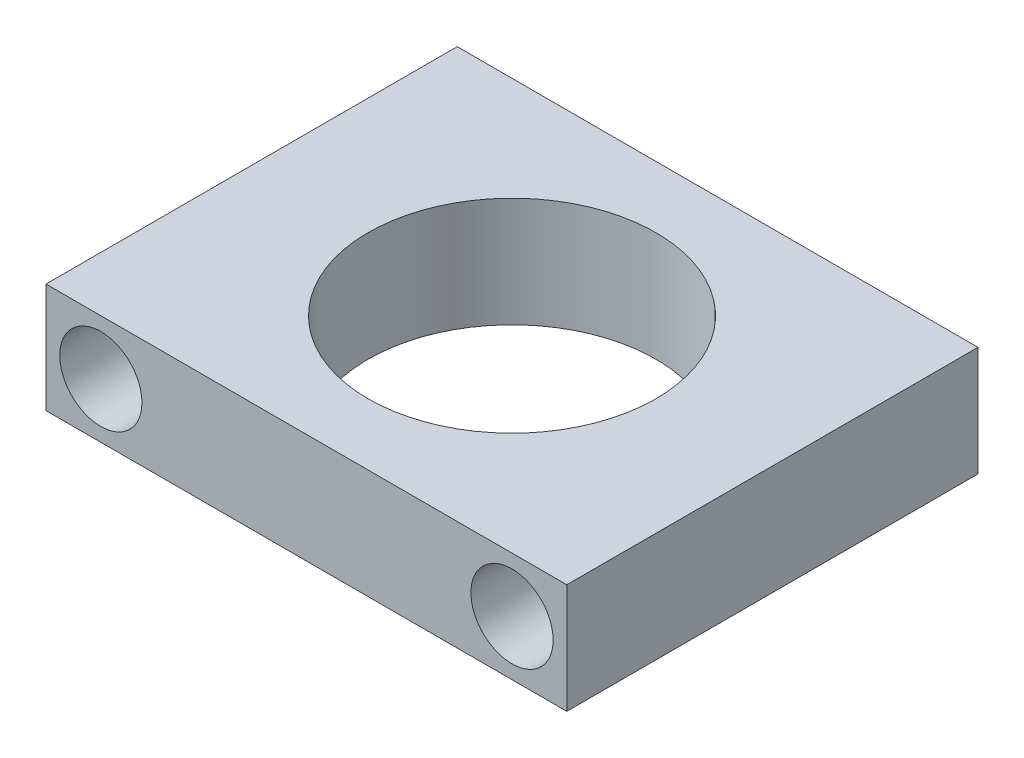
from build123d import *

# Parameters (mm, degrees)
SKETCH1_W           = 19
SKETCH1_H           = 15
SKETCH1_R           = 5.25
BOSS_EXTRUDE1_DEPTH = 4
SKETCH2_R           = 1.5
CUT_EXTRUDE1_DEPTH  = 15


with BuildPart() as part:
    # Sketch1 → Boss-Extrude1 (new body)
    with BuildSketch(Plane(origin=(0, 0, 0), x_dir=(1, 0, 0), z_dir=(0, 1, 0))):
        with Locations((9.5, 7.5)):
            Rectangle(SKETCH1_W, SKETCH1_H)
        with Locations((9.5, 7.5)):
            Circle(SKETCH1_R, mode=Mode.SUBTRACT)
    extrude(amount=BOSS_EXTRUDE1_DEPTH)

    # Sketch2 → Cut-Extrude1 (cut)
    with BuildSketch(Plane.XY):
        with Locations((2, 2)):
            Circle(SKETCH2_R)
        with Locations((17, 2)):
            Circle(SKETCH2_R)
    extrude(amount=-CUT_EXTRUDE1_DEPTH, mode=Mode.SUBTRACT)


solid = part.part
